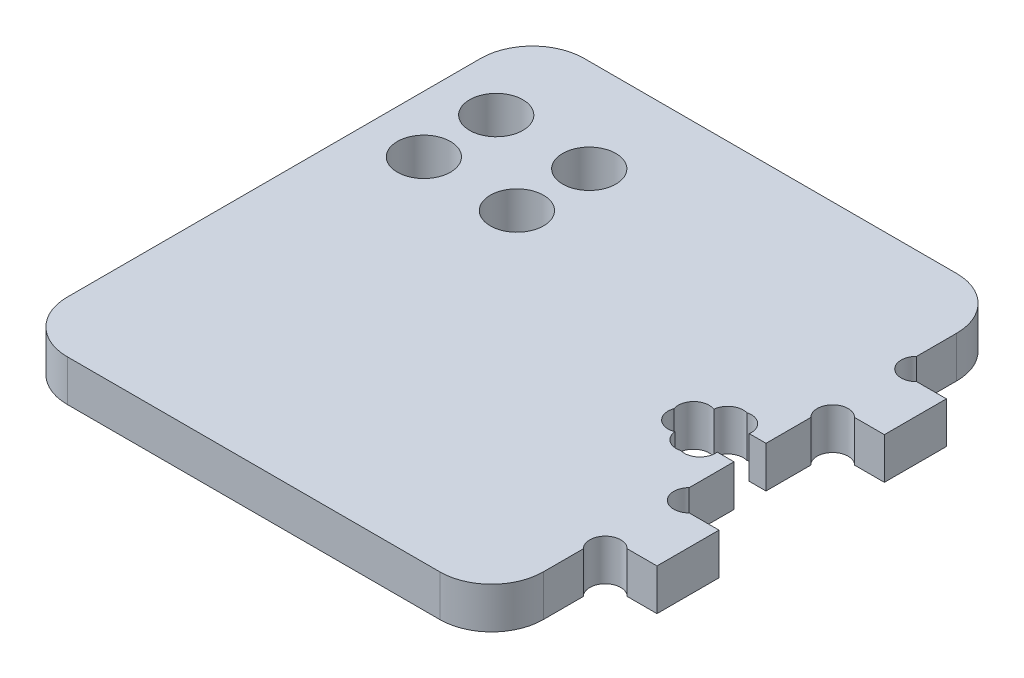
from build123d import *

# Parameters (mm, degrees)
SALIENTE_EXTRUIR1_DEPTH = 4
CORTAR_EXTRUIR4_DEPTH   = 5
CROQUIS10_R             = 1.5
CORTAR_EXTRUIR5_DEPTH   = 5
CROQUIS12_R             = 2.575
CORTAR_EXTRUIR6_DEPTH   = 5


with BuildPart() as part:
    # Croquis1 → Saliente-Extruir1 (new body)
    with BuildSketch(Plane(origin=(0, 0, 0), x_dir=(1, 0, 0), z_dir=(0, 1, 0))):
        with BuildLine():
            Line((-18.025, -25), (18.025, -25))
            ThreePointArc((18.025, -25), (21.560533906, -23.535533906), (23.025, -20))
            Line((23.025, -20), (23.025, -14))
            Line((23.025, -14), (28.025, -14))
            Line((28.025, -14), (28.025, -8))
            Line((28.025, -8), (23.025, -8))
            Line((23.025, -8), (23.025, -1.55))
            Line((23.025, -1.55), (20.975, -1.55))
            Line((20.975, -1.55), (20.975, -2.8))
            Line((20.975, -2.8), (18.075, -2.8))
            Line((18.075, -2.8), (18.075, -1.55))
            Line((18.075, -1.55), (16.025, -1.55))
            Line((16.025, -1.55), (16.025, 1.55))
            Line((16.025, 1.55), (18.075, 1.55))
            Line((18.075, 1.55), (18.075, 2.8))
            Line((18.075, 2.8), (20.975, 2.8))
            Line((20.975, 2.8), (20.975, 1.55))
            Line((20.975, 1.55), (23.025, 1.55))
            Line((23.025, 1.55), (23.025, 8))
            Line((23.025, 8), (28.025, 8))
            Line((28.025, 8), (28.025, 14))
            Line((28.025, 14), (23.025, 14))
            Line((23.025, 14), (23.025, 20))
            ThreePointArc((23.025, 20), (21.560533906, 23.535533906), (18.025, 25))
            Line((18.025, 25), (-18.025, 25))
            ThreePointArc((-18.025, 25), (-21.560533906, 23.535533906), (-23.025, 20))
            Line((-23.025, 20), (-23.025, -20))
            ThreePointArc((-23.025, -20), (-21.560533906, -23.535533906), (-18.025, -25))
        make_face()
    extrude(amount=SALIENTE_EXTRUIR1_DEPTH)

    # Croquis7 → Cortar-Extruir4 (cut, through all)
    with BuildSketch(Plane(origin=(0, 4, 0), x_dir=(1, 0, 0), z_dir=(0, 1, 0))):
        with BuildLine():
            Line((21.402341989, 1.55), (23.025, 1.55))
            Line((23.025, 1.55), (23.025, -1.55))
            Line((23.025, -1.55), (21.402341989, -1.55))
            ThreePointArc((21.402341989, -1.55), (20.900478098, -2.869619136), (19.525, -3.187930349))
            ThreePointArc((19.525, -3.187930349), (18.280747615, -2.971867524), (17.642475162, -1.882163243))
            ThreePointArc((17.642475162, -1.882163243), (16.05076038, -1.575149398), (15.66772275, 0))
            ThreePointArc((15.66772275, 0), (16.05076038, 1.575149398), (17.642475162, 1.882163243))
            ThreePointArc((17.642475162, 1.882163243), (18.280747615, 2.971867524), (19.525, 3.187930349))
            ThreePointArc((19.525, 3.187930349), (20.900478098, 2.869619136), (21.402341989, 1.55))
        make_face()
    extrude(amount=-CORTAR_EXTRUIR4_DEPTH, mode=Mode.SUBTRACT)

    # Croquis10 → Cortar-Extruir5 (cut, through all)
    with BuildSketch(Plane(origin=(0, 4, 0), x_dir=(1, 0, 0), z_dir=(0, 1, 0))):
        with Locations((24.085660172, 15.060660172)):
            Circle(CROQUIS10_R)
        with Locations((24.085660172, 6.939339828)):
            Circle(CROQUIS10_R)
        with Locations((24.085660172, -15.060660172)):
            Circle(CROQUIS10_R)
        with Locations((24.085660172, -6.939339828)):
            Circle(CROQUIS10_R)
    extrude(amount=-CORTAR_EXTRUIR5_DEPTH, mode=Mode.SUBTRACT)

    # Croquis12 → Cortar-Extruir6 (cut, through all)
    with BuildSketch(Plane(origin=(0, 4, 0), x_dir=(1, 0, 0), z_dir=(0, 1, 0))):
        with Locations((-17.525, 16)):
            Circle(CROQUIS12_R)
        with Locations((-8.525, 16)):
            Circle(CROQUIS12_R)
        with Locations((-8.525, 9)):
            Circle(CROQUIS12_R)
        with Locations((-17.525, 9)):
            Circle(CROQUIS12_R)
    extrude(amount=-CORTAR_EXTRUIR6_DEPTH, mode=Mode.SUBTRACT)


solid = part.part
